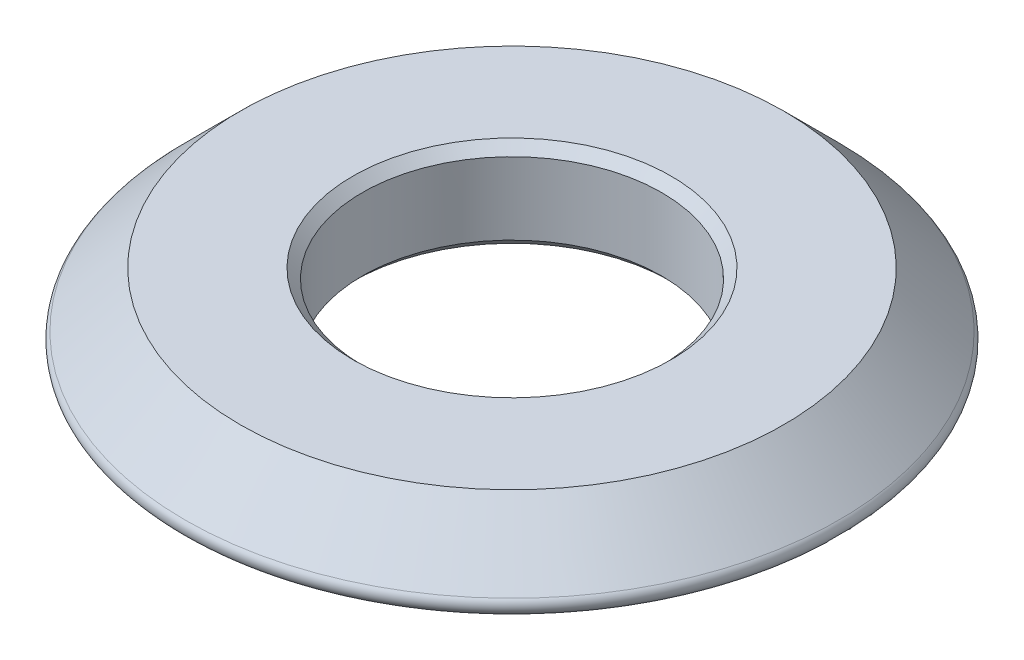
from build123d import *

# Parameters (mm, degrees)
CUT_EXTRUDE1_DEPTH = 0.254
FILLET1_R          = 0.254
CHAMFER1_SIZE      = 0.254


with BuildPart() as part:
    # Sketch1 → Revolve1 (revolve)
    with BuildSketch(Plane(origin=(0, 0, 0), x_dir=(0, 0, -1), z_dir=(1, 0, 0))):
        Polygon((4, 1.905), (7.2644, 1.905), (9.1694, 0), (4.942958634, 0), (4.635, -0.5334), (4, -0.5334), align=None)
    revolve(axis=Axis((0, 0, 0), (0, 1, 0)))

    # Sketch2 → Cut-Extrude1 (cut)
    with BuildSketch(Plane.XZ):
        with BuildLine():
            add(Edge.make_bspline(
                [(-1.749226563, 5.101708634), (-1.789944464, 5.102530819), (-1.869953594, 5.104146382), (-1.987748256, 5.117960667), (-2.100724421, 5.140117417), (-2.209431604, 5.170879723), (-2.313066983, 5.211255615), (-2.412527502, 5.260020323), (-2.50717163, 5.31811087), (-2.566008332, 5.363281012), (-2.5955625, 5.385970352)],
                knots=[0, 0, 0, 0, 0.000122121, 0.000239963, 0.000355254, 0.000467214, 0.000578412, 0.000688457, 0.000799152, 0.000910875, 0.000910875, 0.000910875, 0.000910875], degree=3))
            add(Edge.make_bspline(
                [(-2.5955625, 5.385970352), (-2.625242931, 5.411655291), (-2.683543393, 5.462107518), (-2.75989507, 5.547125206), (-2.824254744, 5.637969334), (-2.877383638, 5.734200767), (-2.918162018, 5.836260654), (-2.947614827, 5.94370962), (-2.965220529, 6.056935606), (-2.967476326, 6.13434806), (-2.968625, 6.173767227)],
                knots=[0, 0, 0, 0, 0.000117666, 0.000231129, 0.000341798, 0.000451034, 0.000560107, 0.00067071, 0.000784654, 0.000902875, 0.000902875, 0.000902875, 0.000902875], degree=3))
            add(Edge.make_bspline(
                [(-2.968625, 6.173767227), (-2.96764207, 6.220619219), (-2.965690559, 6.313639174), (-2.948025846, 6.451488208), (-2.920581548, 6.586329888), (-2.881081103, 6.717931956), (-2.830200289, 6.846264165), (-2.76843626, 6.971460128), (-2.696039828, 7.093888817), (-2.639552278, 7.171033426), (-2.610941406, 7.210107071)],
                knots=[0, 0, 0, 0, 0.000140501, 0.00027895, 0.000416232, 0.000552939, 0.00069057, 0.000829901, 0.000971389, 0.001116603, 0.001116603, 0.001116603, 0.001116603], degree=3))
            add(Edge.make_bspline(
                [(-2.610941406, 7.210107071), (-2.594136609, 7.231626817), (-2.561032278, 7.27401928), (-2.508092249, 7.333549872), (-2.454017907, 7.389403804), (-2.398067206, 7.440962316), (-2.340297363, 7.488162848), (-2.281153065, 7.531611794), (-2.220072598, 7.570679117), (-2.157628619, 7.606135146), (-2.093347637, 7.636776318), (-2.027762264, 7.663963438), (-1.96007048, 7.685878452), (-1.891180747, 7.705064586), (-1.820559081, 7.719472479), (-1.74826299, 7.729037842), (-1.674451526, 7.736013214), (-1.62455845, 7.736641766), (-1.59940625, 7.736958634)],
                knots=[0, 0, 0, 0, 8.1893e-05, 0.000161324, 0.000238856, 0.000315043, 0.000389426, 0.000462555, 0.000535077, 0.000606825, 0.000677829, 0.000748581, 0.000819647, 0.000891135, 0.000963034, 0.001035649, 0.001109848, 0.00118528, 0.00118528, 0.00118528, 0.00118528], degree=3))
            add(Edge.make_bspline(
                [(-1.59940625, 7.736958634), (-1.552077655, 7.736341744), (-1.460208391, 7.735144302), (-1.327132128, 7.721793158), (-1.202983517, 7.701433753), (-1.08802672, 7.67232627), (-0.982190344, 7.634802656), (-0.88584291, 7.588366492), (-0.798033725, 7.534255468), (-0.719839262, 7.470915918), (-0.650691881, 7.399289992), (-0.590521365, 7.319328473), (-0.540624621, 7.230301611), (-0.499087522, 7.133430701), (-0.467594678, 7.027993728), (-0.445057551, 6.914389328), (-0.43084389, 6.792424816), (-0.429379559, 6.708266274), (-0.428625, 6.66490004)],
                knots=[0, 0, 0, 0, 0.000141938, 0.000275516, 0.000400788, 0.000519064, 0.00063079, 0.000737072, 0.000839352, 0.000939531, 0.001038119, 0.001137338, 0.001238867, 0.001343548, 0.001452933, 0.001568321, 0.001690655, 0.001820709, 0.001820709, 0.001820709, 0.001820709], degree=3))
            add(Edge.make_bspline(
                [(-0.428625, 6.66490004), (-0.429518948, 6.61805824), (-0.431289666, 6.525274689), (-0.447253888, 6.387773358), (-0.472831, 6.253532257), (-0.509347413, 6.122745192), (-0.555430033, 5.995204456), (-0.612518657, 5.871307843), (-0.679151262, 5.750190558), (-0.731584692, 5.673626875), (-0.75803125, 5.635009415)],
                knots=[0, 0, 0, 0, 0.000140482, 0.000278265, 0.000414672, 0.000550077, 0.000685198, 0.000821056, 0.000958961, 0.001099306, 0.001099306, 0.001099306, 0.001099306], degree=3))
            add(Edge.make_bspline(
                [(-0.75803125, 5.635009415), (-0.773808143, 5.613306728), (-0.805052766, 5.570326641), (-0.855817299, 5.510368355), (-0.907452322, 5.453578042), (-0.961671969, 5.401805493), (-1.017086139, 5.353291941), (-1.074897645, 5.309808864), (-1.133901305, 5.269751774), (-1.195211845, 5.234534309), (-1.258220537, 5.20335427), (-1.322843488, 5.175753252), (-1.389595442, 5.153092466), (-1.457953816, 5.134105564), (-1.528272204, 5.119797053), (-1.600323766, 5.109462073), (-1.674187197, 5.102697629), (-1.724076343, 5.102040106), (-1.749226563, 5.101708634)],
                knots=[0, 0, 0, 0, 8.0467e-05, 0.000159356, 0.000235544, 0.000310626, 0.00038413, 0.000456362, 0.000527498, 0.000597954, 0.000668283, 0.00073831, 0.000808594, 0.000879604, 0.000951017, 0.001023701, 0.0010979, 0.001173332, 0.001173332, 0.001173332, 0.001173332], degree=3))
        make_face()
        with BuildLine():
            add(Edge.make_bspline(
                [(-1.59940625, 7.292458634), (-1.630257505, 7.291546207), (-1.691145934, 7.289745431), (-1.780406885, 7.271243434), (-1.86665137, 7.243158781), (-1.949173574, 7.202481905), (-2.028309386, 7.15068025), (-2.104057538, 7.087663104), (-2.176176934, 7.01292733), (-2.219556747, 6.956714791), (-2.241847656, 6.927829727)],
                knots=[0, 0, 0, 0, 9.2435e-05, 0.00018243, 0.000272322, 0.000363954, 0.000457522, 0.000555467, 0.000658965, 0.000768363, 0.000768363, 0.000768363, 0.000768363], degree=3))
            add(Edge.make_bspline(
                [(-2.241847656, 6.927829727), (-2.261806843, 6.899346837), (-2.30137213, 6.842884931), (-2.352431531, 6.753750838), (-2.395718615, 6.662349405), (-2.431168984, 6.568645198), (-2.458608272, 6.472563833), (-2.477651886, 6.374113158), (-2.49018959, 6.273473509), (-2.491642127, 6.205554893), (-2.492375, 6.171286759)],
                knots=[0, 0, 0, 0, 0.000104298, 0.00020675, 0.000307721, 0.000407416, 0.000506974, 0.000607088, 0.000708004, 0.000810772, 0.000810772, 0.000810772, 0.000810772], degree=3))
            add(Edge.make_bspline(
                [(-2.492375, 6.171286759), (-2.491685733, 6.148431525), (-2.490330498, 6.103493641), (-2.480308421, 6.037727074), (-2.463474708, 5.975251783), (-2.439400641, 5.916144358), (-2.408466495, 5.86044321), (-2.370988389, 5.807911363), (-2.326509026, 5.758974079), (-2.292765306, 5.729758118), (-2.275582031, 5.714880509)],
                knots=[0, 0, 0, 0, 6.8549e-05, 0.000134781, 0.000199045, 0.000262242, 0.00032575, 0.000389764, 0.000455437, 0.000523581, 0.000523581, 0.000523581, 0.000523581], degree=3))
            add(Edge.make_bspline(
                [(-2.275582031, 5.714880509), (-2.257801876, 5.701302913), (-2.222385608, 5.674257719), (-2.164705091, 5.639797909), (-2.103523635, 5.611285223), (-2.039268336, 5.587130823), (-1.971422005, 5.568990069), (-1.900472736, 5.555580889), (-1.825980975, 5.547435318), (-1.775209627, 5.546623894), (-1.749226563, 5.546208634)],
                knots=[0, 0, 0, 0, 6.7075e-05, 0.000133608, 0.000201071, 0.000269354, 0.000339275, 0.000411469, 0.000485812, 0.000563739, 0.000563739, 0.000563739, 0.000563739], degree=3))
            add(Edge.make_bspline(
                [(-1.749226563, 5.546208634), (-1.718870412, 5.547125071), (-1.658963604, 5.54893363), (-1.571479731, 5.567312988), (-1.487591517, 5.59531743), (-1.408257538, 5.636438595), (-1.33226563, 5.687794278), (-1.26045461, 5.751082392), (-1.192767569, 5.825812393), (-1.152695303, 5.881960361), (-1.132085938, 5.91083754)],
                knots=[0, 0, 0, 0, 9.0949e-05, 0.000179485, 0.000267025, 0.00035555, 0.000446638, 0.000541562, 0.000642008, 0.000748372, 0.000748372, 0.000748372, 0.000748372], degree=3))
            add(Edge.make_bspline(
                [(-1.132085938, 5.91083754), (-1.113953678, 5.93885255), (-1.077928024, 5.994513515), (-1.03182701, 6.082374213), (-0.992464873, 6.172887127), (-0.960171027, 6.266229335), (-0.935137911, 6.362427201), (-0.918240767, 6.461540237), (-0.906629786, 6.563422252), (-0.905464526, 6.632455404), (-0.904875, 6.667380509)],
                knots=[0, 0, 0, 0, 0.000100071, 0.000198823, 0.000297251, 0.000395934, 0.000494841, 0.000595079, 0.000697362, 0.000802096, 0.000802096, 0.000802096, 0.000802096], degree=3))
            add(Edge.make_bspline(
                [(-0.904875, 6.667380509), (-0.905308482, 6.695840947), (-0.906141783, 6.750551739), (-0.913646149, 6.829315074), (-0.925771885, 6.901366855), (-0.942898246, 6.966769691), (-0.965392954, 7.025238818), (-0.991924258, 7.077473309), (-1.024304853, 7.122972626), (-1.050327628, 7.148124725), (-1.063128906, 7.160497696)],
                knots=[0, 0, 0, 0, 8.5364e-05, 0.000164099, 0.000237094, 0.000304362, 0.00036655, 0.000424684, 0.00047976, 0.000533085, 0.000533085, 0.000533085, 0.000533085], degree=3))
            add(Edge.make_bspline(
                [(-1.063128906, 7.160497696), (-1.076750991, 7.171147937), (-1.10497239, 7.193212454), (-1.154520611, 7.219714566), (-1.210930142, 7.242471933), (-1.274575314, 7.261132064), (-1.345447715, 7.275452406), (-1.423596137, 7.284789149), (-1.508997047, 7.291636583), (-1.568467489, 7.292177321), (-1.59940625, 7.292458634)],
                knots=[0, 0, 0, 0, 5.1794e-05, 0.000107303, 0.000167829, 0.000234068, 0.000305967, 0.000384483, 0.000470055, 0.000562845, 0.000562845, 0.000562845, 0.000562845], degree=3))
        make_face(mode=Mode.SUBTRACT)
        with BuildLine():
            add(Edge.make_bspline(
                [(1.285875, 6.169302384), (1.285875, 6.148301082), (1.285875, 6.101668269), (1.285875, 6.024443009), (1.285875, 5.932996394), (1.285875, 5.831958634), (1.285875, 5.731086238), (1.285875, 5.639639623), (1.285875, 5.562414363), (1.285875, 5.515616186), (1.285875, 5.494614884)],
                knots=[0, 0, 0, 0, 6.3004e-05, 0.000139898, 0.000231676, 0.000337344, 0.000443012, 0.000534293, 0.000611684, 0.000674687, 0.000674687, 0.000674687, 0.000674687], degree=3))
            add(Edge.make_bspline(
                [(1.285875, 5.494614884), (1.285875, 5.4880003), (1.285875, 5.473448217), (1.285875, 5.449470352), (1.285875, 5.421193009), (1.285875, 5.389939102), (1.285875, 5.358850561), (1.285875, 5.330573217), (1.285875, 5.306760717), (1.285875, 5.292208634), (1.285875, 5.285759415)],
                knots=[0, 0, 0, 0, 1.9844e-05, 4.3656e-05, 7.1934e-05, 0.000104676, 0.000137418, 0.000165199, 0.000189508, 0.000208855, 0.000208855, 0.000208855, 0.000208855], degree=3))
            add(Edge.make_bspline(
                [(1.285875, 5.285759415), (1.285156113, 5.270796501), (1.283757443, 5.241684576), (1.27152521, 5.1999103), (1.250591534, 5.162665688), (1.222812764, 5.129972983), (1.189231942, 5.103033727), (1.150738775, 5.084070867), (1.108807537, 5.07217011), (1.079580648, 5.07070747), (1.064617188, 5.069958634)],
                knots=[0, 0, 0, 0, 4.4824e-05, 8.7211e-05, 0.00012918, 0.00017212, 0.000215197, 0.000257351, 0.000300078, 0.000344903, 0.000344903, 0.000344903, 0.000344903], degree=3))
            add(Edge.make_bspline(
                [(1.064617188, 5.069958634), (1.053999998, 5.070118802), (1.03343735, 5.070429006), (1.00389284, 5.076416905), (0.976118453, 5.084477983), (0.950923717, 5.097158298), (0.927643371, 5.11253807), (0.907159397, 5.131858881), (0.888553826, 5.154315149), (0.878362315, 5.171341682), (0.873125, 5.180091446)],
                knots=[0, 0, 0, 0, 3.1785e-05, 6.1559e-05, 9.0118e-05, 0.000118295, 0.000145813, 0.000173546, 0.000202447, 0.000233, 0.000233, 0.000233, 0.000233], degree=3))
            add(Edge.make_bspline(
                [(0.873125, 5.180091446), (0.836776995, 5.167971115), (0.764276807, 5.14379575), (0.652140554, 5.120278768), (0.538385474, 5.104433018), (0.461753, 5.102620999), (0.423167969, 5.101708634)],
                knots=[0, 0, 0, 0, 0.000114856, 0.000229094, 0.000343178, 0.000458874, 0.000458874, 0.000458874, 0.000458874], degree=3))
            add(Edge.make_bspline(
                [(0.423167969, 5.101708634), (0.403476934, 5.1019328), (0.364855798, 5.10237247), (0.308062648, 5.107653831), (0.253688718, 5.115334277), (0.201698367, 5.126437887), (0.151966821, 5.140017154), (0.104743171, 5.157774348), (0.059389327, 5.177544571), (0.031267829, 5.194186927), (0.017363281, 5.202415665)],
                knots=[0, 0, 0, 0, 5.9054e-05, 0.000115826, 0.00017097, 0.000223706, 0.000275223, 0.000325449, 0.000374964, 0.000423391, 0.000423391, 0.000423391, 0.000423391], degree=3))
            add(Edge.make_bspline(
                [(0.017363281, 5.202415665), (0.002414995, 5.212355749), (-0.026898445, 5.231848155), (-0.066402981, 5.266086566), (-0.101266747, 5.303256737), (-0.131348402, 5.343906551), (-0.156755576, 5.387859139), (-0.177681899, 5.435204375), (-0.193725521, 5.485961939), (-0.200141468, 5.521316201), (-0.203398437, 5.539263321)],
                knots=[0, 0, 0, 0, 5.381e-05, 0.00010552, 0.000156415, 0.000206422, 0.00025688, 0.000308409, 0.000361443, 0.000416121, 0.000416121, 0.000416121, 0.000416121], degree=3))
            add(Edge.make_bspline(
                [(-0.203398437, 5.539263321), (-0.213742385, 5.607153484), (-0.23380615, 5.738837479), (-0.253359771, 5.931742695), (-0.267676819, 6.113359205), (-0.269158127, 6.230957546), (-0.269875, 6.28786879)],
                knots=[0, 0, 0, 0, 0.000205985, 0.000399541, 0.000581569, 0.000752271, 0.000752271, 0.000752271, 0.000752271], degree=3))
            add(Edge.make_bspline(
                [(-0.269875, 6.28786879), (-0.269467059, 6.325413819), (-0.268621958, 6.403192954), (-0.262243344, 6.523785394), (-0.252466105, 6.652163405), (-0.242997693, 6.740163607), (-0.238125, 6.785450821)],
                knots=[0, 0, 0, 0, 0.000112631, 0.000233328, 0.000362199, 0.000498837, 0.000498837, 0.000498837, 0.000498837], degree=3))
            add(Edge.make_bspline(
                [(-0.238125, 6.785450821), (-0.234814912, 6.800482316), (-0.228519675, 6.829069721), (-0.211678114, 6.868070977), (-0.190367154, 6.901582213), (-0.16315511, 6.928925347), (-0.130416434, 6.949489406), (-0.093014894, 6.964570183), (-0.050348438, 6.973440362), (-0.020217461, 6.974437385), (-0.004464844, 6.974958634)],
                knots=[0, 0, 0, 0, 4.6083e-05, 8.7643e-05, 0.000126721, 0.000164607, 0.000202313, 0.000241926, 0.000285029, 0.000332252, 0.000332252, 0.000332252, 0.000332252], degree=3))
            add(Edge.make_bspline(
                [(-0.004464844, 6.974958634), (0.011817462, 6.974220343), (0.043482298, 6.972784562), (0.088979923, 6.960863564), (0.130940328, 6.942012932), (0.167849815, 6.915019859), (0.199182047, 6.883039383), (0.221839597, 6.845362339), (0.235698126, 6.803598766), (0.237306487, 6.774146469), (0.238125, 6.759157852)],
                knots=[0, 0, 0, 0, 4.8779e-05, 9.4862e-05, 0.000140148, 0.000185996, 0.00023126, 0.000273545, 0.000316845, 0.000361716, 0.000361716, 0.000361716, 0.000361716], degree=3))
            add(Edge.make_bspline(
                [(0.238125, 6.759157852), (0.237892702, 6.745098237), (0.23737306, 6.713647343), (0.234037959, 6.661221423), (0.229112254, 6.598373504), (0.222223366, 6.528311376), (0.215346975, 6.457751402), (0.210364598, 6.393085738), (0.207119927, 6.337841776), (0.206606426, 6.304077845), (0.206375, 6.288860977)],
                knots=[0, 0, 0, 0, 4.218e-05, 9.4354e-05, 0.000157553, 0.000231303, 0.000305547, 0.000370229, 0.000425871, 0.000471523, 0.000471523, 0.000471523, 0.000471523], degree=3))
            add(Edge.make_bspline(
                [(0.206375, 6.288860977), (0.206551176, 6.250824989), (0.206892097, 6.177221123), (0.20990845, 6.07037207), (0.214725318, 5.970953698), (0.22160473, 5.878971233), (0.230405846, 5.794573672), (0.241218763, 5.717779836), (0.253751745, 5.648485875), (0.264688056, 5.605358617), (0.269875, 5.584903946)],
                knots=[0, 0, 0, 0, 0.000114106, 0.000220808, 0.000320646, 0.000412685, 0.000497493, 0.000575158, 0.000645311, 0.000708601, 0.000708601, 0.000708601, 0.000708601], degree=3))
            add(Edge.make_bspline(
                [(0.269875, 5.584903946), (0.283689448, 5.57924263), (0.310479621, 5.568263716), (0.350832648, 5.555604419), (0.390121122, 5.547760252), (0.416024586, 5.546716401), (0.428625, 5.546208634)],
                knots=[0, 0, 0, 0, 4.4772e-05, 8.6826e-05, 0.000126718, 0.000164503, 0.000164503, 0.000164503, 0.000164503], degree=3))
            add(Edge.make_bspline(
                [(0.428625, 5.546208634), (0.460728393, 5.546955908), (0.526729781, 5.548492231), (0.627796449, 5.558856221), (0.733496908, 5.575664942), (0.804747975, 5.591924521), (0.841375, 5.600282852)],
                knots=[0, 0, 0, 0, 9.6305e-05, 0.000197993, 0.000304509, 0.000417187, 0.000417187, 0.000417187, 0.000417187], degree=3))
            add(Edge.make_bspline(
                [(0.841375, 5.600282852), (0.841415667, 5.622607214), (0.841499713, 5.668744802), (0.840822993, 5.74018104), (0.840378876, 5.816083579), (0.840053866, 5.868173479), (0.839886719, 5.89496254)],
                knots=[0, 0, 0, 0, 6.6973e-05, 0.000138412, 0.000214316, 0.000294685, 0.000294685, 0.000294685, 0.000294685], degree=3))
            add(Edge.make_bspline(
                [(0.839886719, 5.89496254), (0.83934216, 5.925554363), (0.838338428, 5.981941263), (0.837635816, 6.059668293), (0.836203467, 6.123492128), (0.836349805, 6.161529729), (0.836414063, 6.178232071)],
                knots=[0, 0, 0, 0, 9.1789e-05, 0.000169186, 0.00023319, 0.000283296, 0.000283296, 0.000283296, 0.000283296], degree=3))
            add(Edge.make_bspline(
                [(0.836414063, 6.178232071), (0.836538832, 6.233794739), (0.836779833, 6.341117506), (0.837783793, 6.496065073), (0.839199299, 6.639273176), (0.840670143, 6.730715729), (0.841375, 6.774536759)],
                knots=[0, 0, 0, 0, 0.000166688, 0.000321969, 0.000464852, 0.000596331, 0.000596331, 0.000596331, 0.000596331], degree=3))
            add(Edge.make_bspline(
                [(0.841375, 6.774536759), (0.844029337, 6.79035627), (0.849075928, 6.82043331), (0.863942087, 6.861986219), (0.885193365, 6.896940025), (0.911859168, 6.92612872), (0.945173533, 6.948249965), (0.983922383, 6.964102434), (1.02828294, 6.973587397), (1.059607388, 6.974487047), (1.076027344, 6.974958634)],
                knots=[0, 0, 0, 0, 4.8062e-05, 9.1379e-05, 0.000131452, 0.000170065, 0.000209004, 0.000250371, 0.000295033, 0.000344236, 0.000344236, 0.000344236, 0.000344236], degree=3))
            add(Edge.make_bspline(
                [(1.076027344, 6.974958634), (1.092467892, 6.974206508), (1.124445031, 6.97274361), (1.170585782, 6.960995782), (1.212979303, 6.9413214), (1.250609045, 6.914351373), (1.282220172, 6.881934299), (1.304962693, 6.844228711), (1.317232448, 6.80192043), (1.317492315, 6.772626641), (1.317625, 6.757669571)],
                knots=[0, 0, 0, 0, 4.9273e-05, 9.5838e-05, 0.000141782, 0.000188725, 0.000233989, 0.000276699, 0.000319562, 0.000364279, 0.000364279, 0.000364279, 0.000364279], degree=3))
            add(Edge.make_bspline(
                [(1.317625, 6.757669571), (1.316270952, 6.732039625), (1.313659138, 6.682602205), (1.310379923, 6.610981278), (1.306702891, 6.544854154), (1.303941627, 6.483980575), (1.300730558, 6.428603874), (1.298509637, 6.37847683), (1.295752484, 6.333684454), (1.294054699, 6.294144047), (1.291792306, 6.259919863), (1.290615414, 6.231171288), (1.288774807, 6.207743285), (1.288254751, 6.190039215), (1.286604401, 6.176543956), (1.287001502, 6.170391397), (1.285621102, 6.164409681), (1.285776933, 6.167412591), (1.285875, 6.169302384)],
                knots=[0, 0, 0, 0, 7.6997e-05, 0.000148519, 0.000215086, 0.000275683, 0.000331325, 0.000381492, 0.000426209, 0.000465946, 0.000500234, 0.000529046, 0.00055241, 0.000570297, 0.000583233, 0.000590691, 0.000592736, 0.000596209, 0.000596209, 0.000596209, 0.000596209], degree=3))
        make_face()
        with BuildLine():
            add(Edge.make_bspline(
                [(2.826246094, 6.538396134), (2.813179783, 6.538471068), (2.784718625, 6.538634289), (2.741082662, 6.540860789), (2.697448551, 6.543129027), (2.669152366, 6.543285032), (2.656085938, 6.543357071)],
                knots=[0, 0, 0, 0, 3.9195e-05, 8.5374e-05, 0.000131058, 0.000170252, 0.000170252, 0.000170252, 0.000170252], degree=3))
            add(Edge.make_bspline(
                [(2.656085938, 6.543357071), (2.630586374, 6.542803476), (2.57577913, 6.541613612), (2.521435022, 6.534345299), (2.492375, 6.530458634)],
                knots=[0, 0, 0, 0, 7.6456e-05, 0.000164331, 0.000164331, 0.000164331, 0.000164331], degree=3))
            add(Edge.make_bspline(
                [(2.492375, 6.530458634), (2.494776869, 6.477214761), (2.499363765, 6.375533901), (2.504562686, 6.230154508), (2.509462322, 6.099349131), (2.514276237, 5.982956327), (2.517176399, 5.881079701), (2.519009089, 5.79359488), (2.520787235, 5.720674958), (2.52103716, 5.676847425), (2.521148437, 5.657333634)],
                knots=[0, 0, 0, 0, 0.000159893, 0.000305351, 0.000436414, 0.000552585, 0.000654824, 0.000742159, 0.0008151, 0.000873641, 0.000873641, 0.000873641, 0.000873641], degree=3))
            add(Edge.make_bspline(
                [(2.521148437, 5.657333634), (2.521120521, 5.653033754), (2.521053934, 5.642777898), (2.521761293, 5.625089901), (2.522173463, 5.602598665), (2.522774754, 5.568366995), (2.52366073, 5.527690831), (2.523983192, 5.49610353), (2.524125, 5.48221254)],
                knots=[0, 0, 0, 0, 1.2898e-05, 3.0765e-05, 5.3094e-05, 8.0384e-05, 0.000133475, 0.00017515, 0.00017515, 0.00017515, 0.00017515], degree=3))
            add(Edge.make_bspline(
                [(2.524125, 5.48221254), (2.523515521, 5.452397373), (2.522371616, 5.396438497), (2.510163559, 5.31850136), (2.490177074, 5.252160132), (2.462029207, 5.197244234), (2.425024668, 5.153691009), (2.37875983, 5.123142568), (2.32422139, 5.104587538), (2.285162411, 5.102699367), (2.264667969, 5.101708634)],
                knots=[0, 0, 0, 0, 8.9385e-05, 0.000167763, 0.00023586, 0.000296442, 0.000351652, 0.000405312, 0.000460848, 0.000522158, 0.000522158, 0.000522158, 0.000522158], degree=3))
            add(Edge.make_bspline(
                [(2.264667969, 5.101708634), (2.248704667, 5.102244612), (2.217697927, 5.103285684), (2.173233283, 5.115253155), (2.131266092, 5.131807688), (2.10709403, 5.149442786), (2.095003906, 5.158263321)],
                knots=[0, 0, 0, 0, 4.7751e-05, 9.2751e-05, 0.000137438, 0.000182156, 0.000182156, 0.000182156, 0.000182156], degree=3))
            add(Edge.make_bspline(
                [(2.095003906, 5.158263321), (2.082837018, 5.16829323), (2.059498086, 5.187532937), (2.034879094, 5.22465549), (2.018722902, 5.264963053), (2.017001201, 5.293540249), (2.016125, 5.308083634)],
                knots=[0, 0, 0, 0, 4.7053e-05, 9.0259e-05, 0.000132181, 0.000175625, 0.000175625, 0.000175625, 0.000175625], degree=3))
            add(Edge.make_bspline(
                [(2.016125, 5.308083634), (2.01626899, 5.319328805), (2.016588764, 5.344302201), (2.017637697, 5.385478443), (2.019176547, 5.434094146), (2.02089858, 5.4876836), (2.023705123, 5.541395382), (2.024979278, 5.590193373), (2.026087766, 5.631532703), (2.026401637, 5.656506328), (2.026542969, 5.667751602)],
                knots=[0, 0, 0, 0, 3.3738e-05, 7.4926e-05, 0.000123566, 0.000179659, 0.000235773, 0.000284909, 0.000326096, 0.000359834, 0.000359834, 0.000359834, 0.000359834], degree=3))
            add(Edge.make_bspline(
                [(2.026542969, 5.667751602), (2.026568765, 5.686933949), (2.026626806, 5.7300948), (2.026070556, 5.802029676), (2.0249217, 5.888346479), (2.02410587, 5.989057307), (2.022571518, 6.103985795), (2.020422355, 6.233296003), (2.018635424, 6.377003183), (2.016987966, 6.477707866), (2.016125, 6.530458634)],
                knots=[0, 0, 0, 0, 5.7547e-05, 0.000129482, 0.000215808, 0.00031652, 0.000431623, 0.000560623, 0.000704504, 0.000862777, 0.000862777, 0.000862777, 0.000862777], degree=3))
            add(Edge.make_bspline(
                [(2.016125, 6.530458634), (1.99594376, 6.531515671), (1.951075739, 6.533865735), (1.877023092, 6.540218579), (1.78937051, 6.548249854), (1.70930317, 6.555496495), (1.643467135, 6.565103996), (1.598650135, 6.578721298), (1.560835535, 6.598746246), (1.5295784, 6.624038578), (1.505152387, 6.654961784), (1.488140439, 6.691642858), (1.478232679, 6.733671473), (1.477014313, 6.76340142), (1.476375, 6.779001602)],
                knots=[0, 0, 0, 0, 6.0623e-05, 0.00013478, 0.000222947, 0.000324685, 0.000375984, 0.00042227, 0.000464438, 0.000503567, 0.000542074, 0.000581575, 0.000623929, 0.000670691, 0.000670691, 0.000670691, 0.000670691], degree=3))
            add(Edge.make_bspline(
                [(1.476375, 6.779001602), (1.477001108, 6.794323897), (1.478229869, 6.824394468), (1.492046213, 6.867292919), (1.512956456, 6.90686029), (1.542669681, 6.941278031), (1.578035164, 6.971041465), (1.620067267, 6.991860957), (1.666771499, 7.004807335), (1.699527983, 7.006060126), (1.716484375, 7.006708634)],
                knots=[0, 0, 0, 0, 4.5813e-05, 8.9909e-05, 0.000133858, 0.000179274, 0.000225454, 0.000271601, 0.000318897, 0.000369654, 0.000369654, 0.000369654, 0.000369654], degree=3))
            add(Edge.make_bspline(
                [(1.716484375, 7.006708634), (1.722769943, 7.006587091), (1.737172953, 7.006308582), (1.761321367, 7.004681232), (1.790917137, 7.002121868), (1.82565433, 6.998714708), (1.865823257, 6.994100591), (1.911143101, 6.988718369), (1.961903621, 6.982207862), (1.997441141, 6.977456607), (2.016125, 6.974958634)],
                knots=[0, 0, 0, 0, 1.8858e-05, 4.3212e-05, 7.2587e-05, 0.00010798, 0.000147918, 0.000193884, 0.000244895, 0.000301445, 0.000301445, 0.000301445, 0.000301445], degree=3))
            add(Edge.make_bspline(
                [(2.016125, 6.974958634), (2.016125, 6.985045873), (2.016125, 7.007866186), (2.016125, 7.046396134), (2.016125, 7.093194311), (2.016125, 7.127259415), (2.016125, 7.145614884)],
                knots=[0, 0, 0, 0, 3.0262e-05, 6.8461e-05, 0.00011559, 0.000170656, 0.000170656, 0.000170656, 0.000170656], degree=3))
            add(Edge.make_bspline(
                [(2.016125, 7.145614884), (2.016125, 7.161820613), (2.016125, 7.192413061), (2.016125, 7.235242488), (2.016125, 7.272284154), (2.016125, 7.294939102), (2.016125, 7.305357071)],
                knots=[0, 0, 0, 0, 4.8617e-05, 9.1777e-05, 0.000128488, 0.000159742, 0.000159742, 0.000159742, 0.000159742], degree=3))
            add(Edge.make_bspline(
                [(2.016125, 7.305357071), (2.017035969, 7.319824522), (2.018819902, 7.348155843), (2.031328842, 7.388838272), (2.053664497, 7.424950515), (2.083505689, 7.456451904), (2.119153628, 7.48248828), (2.159485264, 7.501107218), (2.203121531, 7.513118586), (2.233663867, 7.514170489), (2.249289063, 7.514708634)],
                knots=[0, 0, 0, 0, 4.339e-05, 8.4971e-05, 0.000126149, 0.00016967, 0.000214423, 0.0002577, 0.000302343, 0.000349105, 0.000349105, 0.000349105, 0.000349105], degree=3))
            add(Edge.make_bspline(
                [(2.249289063, 7.514708634), (2.259236895, 7.514492699), (2.278604475, 7.514072293), (2.306704652, 7.508759102), (2.332948178, 7.501078304), (2.357366599, 7.489917269), (2.379643581, 7.475433759), (2.400363114, 7.4579296), (2.418440291, 7.436889392), (2.435363703, 7.413217508), (2.449384566, 7.385833837), (2.461857219, 7.355468669), (2.472061091, 7.322006981), (2.481119012, 7.285629512), (2.488076577, 7.246025355), (2.492154295, 7.203059914), (2.49536996, 7.157072921), (2.495685238, 7.125281518), (2.495847656, 7.108903946)],
                knots=[0, 0, 0, 0, 2.9803e-05, 5.8024e-05, 8.5488e-05, 0.000111683, 0.000138241, 0.000164984, 0.000192752, 0.000221242, 0.000252088, 0.000284792, 0.000319625, 0.000356925, 0.000397215, 0.000440112, 0.000486345, 0.000535468, 0.000535468, 0.000535468, 0.000535468], degree=3))
            Line((2.495847656, 7.108903946), (2.492375, 6.974958634))
            add(Edge.make_bspline(
                [(2.492375, 6.974958634), (2.509076823, 6.974958634), (2.540826823, 6.974958634), (2.585971354, 6.974958634), (2.626154948, 6.974958634), (2.651290365, 6.974958634), (2.66303125, 6.974958634)],
                knots=[0, 0, 0, 0, 5.0105e-05, 9.525e-05, 0.000135434, 0.000170656, 0.000170656, 0.000170656, 0.000170656], degree=3))
            add(Edge.make_bspline(
                [(2.66303125, 6.974958634), (2.678575433, 6.974818934), (2.708343929, 6.974551397), (2.751193545, 6.973759848), (2.790215102, 6.971623064), (2.825476511, 6.969355251), (2.856782052, 6.96598549), (2.884058072, 6.961453845), (2.907615663, 6.95665356), (2.921847437, 6.95255091), (2.928441406, 6.95065004)],
                knots=[0, 0, 0, 0, 4.6635e-05, 8.9311e-05, 0.000128553, 0.000163863, 0.000195309, 0.000222957, 0.000246795, 0.000267376, 0.000267376, 0.000267376, 0.000267376], degree=3))
            add(Edge.make_bspline(
                [(2.928441406, 6.95065004), (2.939190548, 6.946705955), (2.959920269, 6.939099786), (2.987455276, 6.92222354), (3.011512177, 6.902773113), (3.030839614, 6.879223473), (3.046001632, 6.8525471), (3.056409782, 6.822452657), (3.062966382, 6.789209083), (3.063565264, 6.76580512), (3.063875, 6.753700821)],
                knots=[0, 0, 0, 0, 3.427e-05, 6.609e-05, 9.6388e-05, 0.000126686, 0.000156899, 0.000187967, 0.000221826, 0.000258095, 0.000258095, 0.000258095, 0.000258095], degree=3))
            add(Edge.make_bspline(
                [(3.063875, 6.753700821), (3.063266401, 6.738866401), (3.062078409, 6.709909455), (3.048162365, 6.668816422), (3.027208752, 6.631076626), (2.997148698, 6.598851191), (2.961487413, 6.571873223), (2.920424869, 6.552085597), (2.874647962, 6.540655161), (2.842681271, 6.539163201), (2.826246094, 6.538396134)],
                knots=[0, 0, 0, 0, 4.433e-05, 8.6533e-05, 0.000128745, 0.000172995, 0.000217643, 0.000262242, 0.000308806, 0.00035808, 0.00035808, 0.00035808, 0.00035808], degree=3))
        make_face()
    extrude(amount=-CUT_EXTRUDE1_DEPTH, mode=Mode.SUBTRACT)

    # Fillet1
    fillet1_edges = [part.edges().sort_by_distance(p)[0] for p in [
        (0, 0, 9.1694),
    ]]
    fillet(fillet1_edges, radius=FILLET1_R)

    # Chamfer1
    chamfer1_edges = [part.edges().sort_by_distance(p)[0] for p in [
        (0, -0.5334, 4),
        (0, 1.905, 4),
    ]]
    chamfer(chamfer1_edges, length=CHAMFER1_SIZE)


solid = part.part
